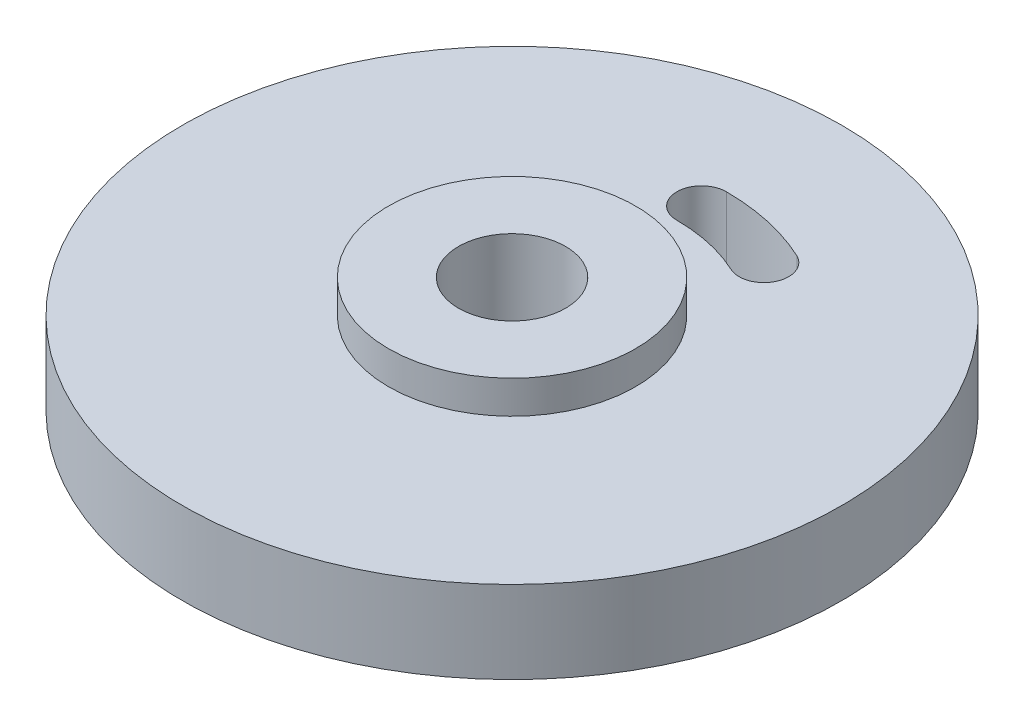
from build123d import *

# Parameters (mm, degrees)
CORTE_EXTRUS_O3_REACH         = 16
ESBO_O4_R                     = 7.5
ESBO_O4_R_2                   = 3.25
RESSALTO_EXTRUS_O1_DEPTH      = 2
RESSALTO_EXTRUS_O1_DEPTH_BACK = 7


with BuildPart() as part:
    # Esboço1 → Revolução1 (revolve)
    with BuildSketch(Plane.XY):
        Polygon((3.25, 14), (3.25, 11.5), (5, 11.5), (5, 9), (20, 9), (20, 14), align=None)
    revolve(axis=Axis((0, 0, 0), (0, 1, 0)))

    # Esboço2 → Corte-extrusão3 (cut, up to next)
    with BuildSketch(Plane(origin=(0, 0, 0), x_dir=(1, 0, 0), z_dir=(0, 1, 0)), mode=Mode.PRIVATE) as corte_extrus_o3_sk1:
        with BuildLine():
            ThreePointArc((4.226182617, 9.06307787), (2.164396139, 9.762960071), (0, 10))
            ThreePointArc((0, 10), (-1.5, 11.5), (0, 13))
            ThreePointArc((0, 13), (2.813714981, 12.691848093), (5.494037403, 11.782001231))
            ThreePointArc((5.494037403, 11.782001231), (6.219571691, 9.788612158), (4.226182617, 9.06307787))
        make_face()
    corte_extrus_o3_tool1 = extrude(corte_extrus_o3_sk1.sketch, amount=CORTE_EXTRUS_O3_REACH, mode=Mode.PRIVATE) & part.part
    add(corte_extrus_o3_tool1.solids().sort_by_distance((2.456799, 0, -11.081905))[0], mode=Mode.SUBTRACT)

    # Esboço4 → Ressalto-extrusão1 (add, two sides)
    with BuildSketch(Plane(origin=(0, 14, 0), x_dir=(1, 0, 0), z_dir=(0, 1, 0))) as ressalto_extrus_o1_sk:
        Circle(ESBO_O4_R)
        Circle(ESBO_O4_R_2, mode=Mode.SUBTRACT)
    extrude(amount=RESSALTO_EXTRUS_O1_DEPTH)
    extrude(ressalto_extrus_o1_sk.sketch, amount=-RESSALTO_EXTRUS_O1_DEPTH_BACK)


solid = part.part
